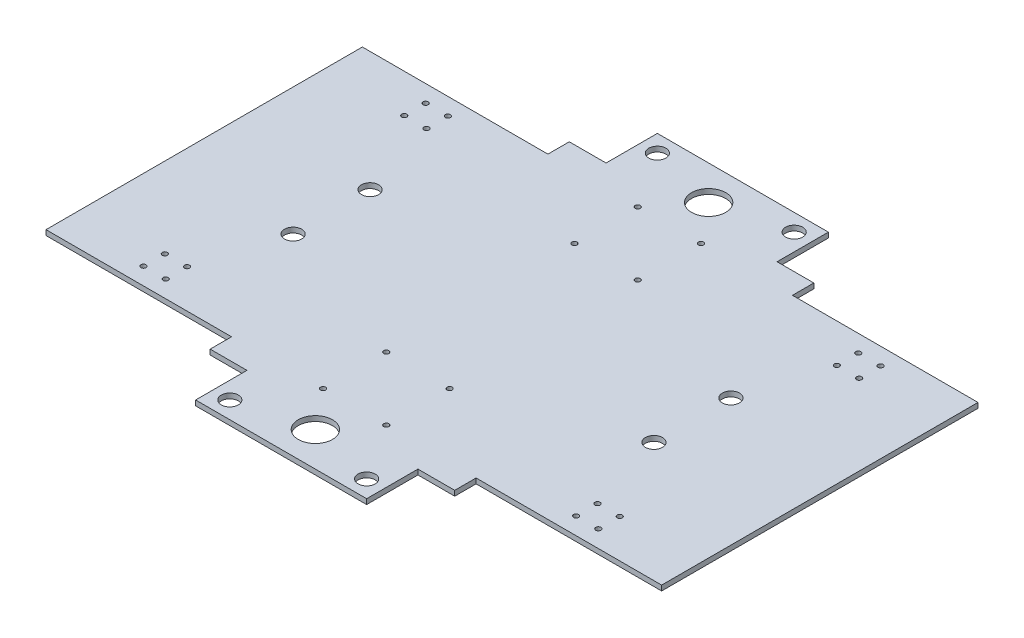
from build123d import *

# Parameters (mm, degrees)
SKETCH1_R           = 1.5
SKETCH1_R_2         = 5
SKETCH1_R_3         = 10
BOSS_EXTRUDE2_DEPTH = 3


with BuildPart() as part:
    # Sketch1 → Boss-Extrude2 (new body)
    with BuildSketch(Plane(origin=(0, 0, 0), x_dir=(1, 0, 0), z_dir=(0, 1, 0))):
        Polygon((-71.5, 92.5), (-180, 92.5), (-180, -92.5), (-71.5, -92.5), (-71.5, -105), (-50, -105), (-50, -135), (50, -135), (50, -105), (71.5, -105), (71.5, -92.5), (180, -92.5), (180, 92.5), (71.5, 92.5), (71.5, 105), (50, 105), (50, 135), (-50, 135), (-50, 105), (-71.5, 105), align=None)
        with Locations((133, -70)):
            Circle(SKETCH1_R, mode=Mode.SUBTRACT)
        with Locations((120, -70)):
            Circle(SKETCH1_R, mode=Mode.SUBTRACT)
        with Locations((133, -82.5)):
            Circle(SKETCH1_R, mode=Mode.SUBTRACT)
        with Locations((120, -82.5)):
            Circle(SKETCH1_R, mode=Mode.SUBTRACT)
        with Locations((-120, -82.5)):
            Circle(SKETCH1_R, mode=Mode.SUBTRACT)
        with Locations((-133, -82.5)):
            Circle(SKETCH1_R, mode=Mode.SUBTRACT)
        with Locations((-120, -70)):
            Circle(SKETCH1_R, mode=Mode.SUBTRACT)
        with Locations((-133, -70)):
            Circle(SKETCH1_R, mode=Mode.SUBTRACT)
        with Locations((-133, 70)):
            Circle(SKETCH1_R, mode=Mode.SUBTRACT)
        with Locations((-120, 70)):
            Circle(SKETCH1_R, mode=Mode.SUBTRACT)
        with Locations((-133, 82.5)):
            Circle(SKETCH1_R, mode=Mode.SUBTRACT)
        with Locations((-120, 82.5)):
            Circle(SKETCH1_R, mode=Mode.SUBTRACT)
        with Locations((133, 82.5)):
            Circle(SKETCH1_R, mode=Mode.SUBTRACT)
        with Locations((120, 82.5)):
            Circle(SKETCH1_R, mode=Mode.SUBTRACT)
        with Locations((120, 70)):
            Circle(SKETCH1_R, mode=Mode.SUBTRACT)
        with Locations((133, 70)):
            Circle(SKETCH1_R, mode=Mode.SUBTRACT)
        with Locations((105.5, 22.5)):
            Circle(SKETCH1_R_2, mode=Mode.SUBTRACT)
        with Locations((105.5, -22.5)):
            Circle(SKETCH1_R_2, mode=Mode.SUBTRACT)
        with Locations((-105.5, -22.5)):
            Circle(SKETCH1_R_2, mode=Mode.SUBTRACT)
        with Locations((-105.5, 22.5)):
            Circle(SKETCH1_R_2, mode=Mode.SUBTRACT)
        with Locations((18.5, -55)):
            Circle(SKETCH1_R, mode=Mode.SUBTRACT)
        with Locations((-18.5, -55)):
            Circle(SKETCH1_R, mode=Mode.SUBTRACT)
        with Locations((18.5, -92)):
            Circle(SKETCH1_R, mode=Mode.SUBTRACT)
        with Locations((-18.5, -92)):
            Circle(SKETCH1_R, mode=Mode.SUBTRACT)
        with Locations((18.5, 92)):
            Circle(SKETCH1_R, mode=Mode.SUBTRACT)
        with Locations((-18.5, 92)):
            Circle(SKETCH1_R, mode=Mode.SUBTRACT)
        with Locations((-18.5, 55)):
            Circle(SKETCH1_R, mode=Mode.SUBTRACT)
        with Locations((18.5, 55)):
            Circle(SKETCH1_R, mode=Mode.SUBTRACT)
        with Locations((-40, -125)):
            Circle(SKETCH1_R_2, mode=Mode.SUBTRACT)
        with Locations((40, -125)):
            Circle(SKETCH1_R_2, mode=Mode.SUBTRACT)
        with Locations((40, 125)):
            Circle(SKETCH1_R_2, mode=Mode.SUBTRACT)
        with Locations((-40, 125)):
            Circle(SKETCH1_R_2, mode=Mode.SUBTRACT)
        with Locations((0, 115)):
            Circle(SKETCH1_R_3, mode=Mode.SUBTRACT)
        with Locations((0, -115)):
            Circle(SKETCH1_R_3, mode=Mode.SUBTRACT)
    extrude(amount=BOSS_EXTRUDE2_DEPTH)


solid = part.part
